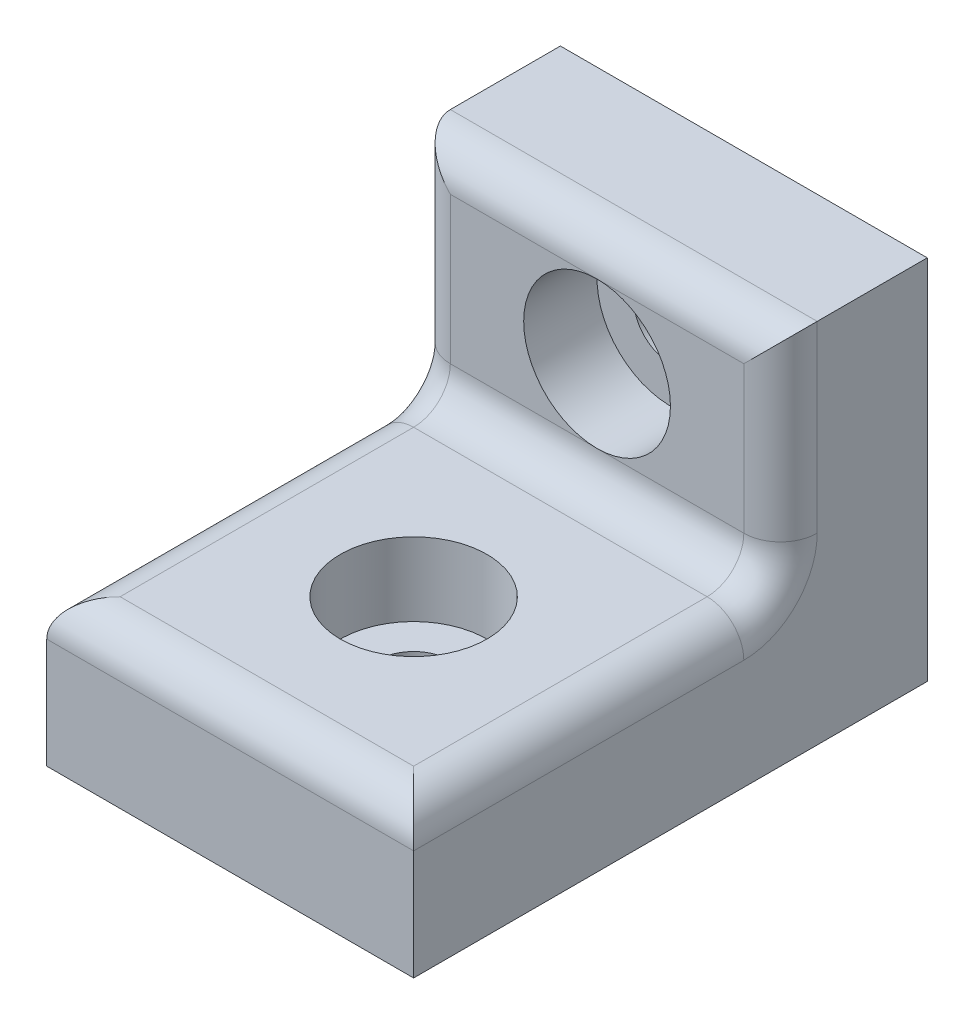
from build123d import *

# Parameters (mm, degrees)
ESQUISSE1_W             = 10
ESQUISSE1_H             = 10
BOSS_EXTRU_1_DEPTH      = 4
ESQUISSE2_W             = 10
ESQUISSE2_H             = 4
BOSS_EXTRU_2_DEPTH      = 10
ESQUISSE3_R             = 1
ENL_V_MAT_EXTRU_1_DEPTH = 5
CONG_1_R                = 1
ESQUISSE4_R             = 1
ENL_V_MAT_EXTRU_2_DEPTH = 5
ESQUISSE5_R             = 2
ENL_V_MAT_EXTRU_3_DEPTH = 2
ESQUISSE6_R             = 2
ENL_V_MAT_EXTRU_4_DEPTH = 2


with BuildPart() as part:
    # Esquisse1 → Boss.-Extru.1 (new body)
    with BuildSketch(Plane.XY):
        with Locations((0, 5)):
            Rectangle(ESQUISSE1_W, ESQUISSE1_H)
    extrude(amount=BOSS_EXTRU_1_DEPTH)

    # Esquisse2 → Boss.-Extru.2 (add)
    with BuildSketch(Plane.XY.offset(4)):
        with Locations((0, 2)):
            Rectangle(ESQUISSE2_W, ESQUISSE2_H)
    extrude(amount=BOSS_EXTRU_2_DEPTH)

    # Esquisse3 → Enlèv. mat.-Extru.1 (cut, through all)
    with BuildSketch(Plane.XY.offset(4)):
        with Locations((0, 7)):
            Circle(ESQUISSE3_R)
    extrude(amount=-ENL_V_MAT_EXTRU_1_DEPTH, mode=Mode.SUBTRACT)

    # Congé1
    cong_1_edges = [part.edges().sort_by_distance(p)[0] for p in [
        (5, 7, 4),
        (-5, 4, 9),
        (0, 4, 4),
        (5, 4, 9),
        (0, 10, 4),
        (0, 4, 14),
        (-5, 7, 4),
    ]]
    fillet(cong_1_edges, radius=CONG_1_R)

    # Esquisse4 → Enlèv. mat.-Extru.2 (cut, through all)
    with BuildSketch(Plane(origin=(0, 4, 0), x_dir=(1, 0, 0), z_dir=(0, 1, 0))):
        with Locations(Location((0, -9, 0), (0, 0, 270))):  # turned: the seam where the file's is
            Circle(ESQUISSE4_R)
    extrude(amount=-ENL_V_MAT_EXTRU_2_DEPTH, mode=Mode.SUBTRACT)

    # Esquisse5 → Enlèv. mat.-Extru.3 (cut)
    with BuildSketch(Plane.XY.offset(4)):
        with Locations((0, 7)):
            Circle(ESQUISSE5_R)
    extrude(amount=-ENL_V_MAT_EXTRU_3_DEPTH, mode=Mode.SUBTRACT)

    # Esquisse6 → Enlèv. mat.-Extru.4 (cut)
    with BuildSketch(Plane(origin=(0, 4, 0), x_dir=(1, 0, 0), z_dir=(0, 1, 0))):
        with Locations(Location((0, -9, 0), (0, 0, 270))):  # turned: the seam where the file's is
            Circle(ESQUISSE6_R)
    extrude(amount=-ENL_V_MAT_EXTRU_4_DEPTH, mode=Mode.SUBTRACT)


solid = part.part
